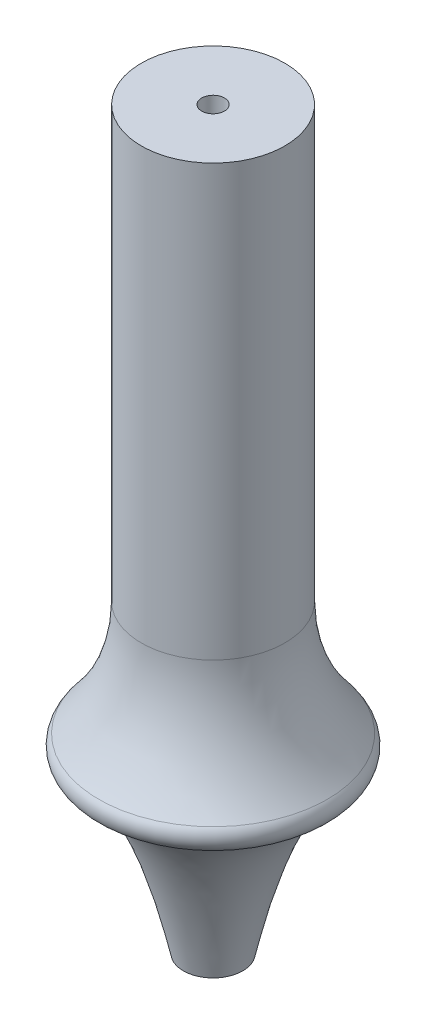
from build123d import *


with BuildPart() as part:
    # Sketch2 → Revolve1 (revolve)
    with BuildSketch(Plane(origin=(0, 0, 0), x_dir=(0, 0, -1), z_dir=(1, 0, 0))):
        with BuildLine():
            Line((-10, 79.984026871), (-10, 20))
            ThreePointArc((-10, 20), (-11.529300925, 11.508521396), (-15.925023202, 4.084129443))
            ThreePointArc((-15.925023202, 4.084129443), (-16.348258147, 2.040451452), (-14.8325, 0.6058))
            add(Edge.make_bspline(
                [(-14.8325, 0.6058), (-14.786589527, 0.594107912), (-14.720151881, 0.577188139), (-14.636942478, 0.555651214), (-14.584628983, 0.541606051), (-14.538694782, 0.529056302), (-14.496115893, 0.516807178), (-14.455377323, 0.504752713), (-14.415703886, 0.492601586), (-14.376608725, 0.480213978), (-14.337823066, 0.467258765), (-14.299073296, 0.453804959), (-14.260077477, 0.439967714), (-14.220832936, 0.425142489), (-14.181003545, 0.409828499), (-14.140639226, 0.39342794), (-14.099539827, 0.376264866), (-14.057643188, 0.358051468), (-14.015003626, 0.338576095), (-13.971270318, 0.318244004), (-13.926716478, 0.296334648), (-13.88091734, 0.273357564), (-13.834012449, 0.248879897), (-13.785997304, 0.222646856), (-13.736545511, 0.195147367), (-13.685880417, 0.165637059), (-13.63383256, 0.134329981), (-13.580202235, 0.101238986), (-13.525196985, 0.065829097), (-13.468489978, 0.028394376), (-13.410218497, -0.011527982), (-13.350168278, -0.053791023), (-13.288470654, -0.098900311), (-13.224788811, -0.146603335), (-13.159241207, -0.197326808), (-13.091855296, -0.251341181), (-13.022233522, -0.308401649), (-12.950733187, -0.369268693), (-12.87684498, -0.433607317), (-12.800942833, -0.50216692), (-12.722558879, -0.574690204), (-12.64180647, -0.651653184), (-12.558631713, -0.733330072), (-12.473007863, -0.820056033), (-12.384606656, -0.911877967), (-12.293655943, -1.009413525), (-12.19993662, -1.112809578), (-12.103181234, -1.222292158), (-12.003658589, -1.33855085), (-11.901000777, -1.461694366), (-11.795279131, -1.592272191), (-11.686428516, -1.730738869), (-11.574152693, -1.877409894), (-11.458536394, -2.032929305), (-11.339441079, -2.197751566), (-11.216906306, -2.372586938), (-11.090456233, -2.557718159), (-10.960339372, -2.754078467), (-10.826403135, -2.962267921), (-10.688322214, -3.182881678), (-10.546388799, -3.416882377), (-10.399982006, -3.664853532), (-10.249381335, -3.927893894), (-10.094533615, -4.206969526), (-9.93478729, -4.502781144), (-9.770600526, -4.816720029), (-9.601692365, -5.149846675), (-9.427661931, -5.50326599), (-9.248775965, -5.878475674), (-9.064645901, -6.276835238), (-8.87533319, -6.699902872), (-8.680516638, -7.149341121), (-8.480119182, -7.626897717), (-8.27419422, -8.134593345), (-8.062173697, -8.674341942), (-7.844473046, -9.248617697), (-7.620378546, -9.859652358), (-7.390143634, -10.510239162), (-7.15351637, -11.203263925), (-6.91022293, -11.941816272), (-6.660409366, -12.729407317), (-6.403463868, -13.569619022), (-6.13955877, -14.466660747), (-5.86859751, -15.425045871), (-5.58995818, -16.449575), (-5.30410545, -17.54587051), (-5.010246169, -18.719716622), (-4.708679684, -19.977884286), (-4.417462856, -21.247043384), (-4.229902291, -22.098318051), (-4.143040834, -22.5)],
                knots=[0, 0, 0, 0, 0.0026864, 0.003887524, 0.004873731, 0.005757813, 0.006587588, 0.007385986, 0.008166831, 0.008940344, 0.009711391, 0.010485479, 0.011266269, 0.012057584, 0.012864206, 0.013685875, 0.014528001, 0.015389717, 0.016276196, 0.017186037, 0.018124349, 0.019091365, 0.020091502, 0.021124214, 0.022193786, 0.02329991, 0.024448714, 0.025637823, 0.026873089, 0.028157979, 0.029490658, 0.030878236, 0.032321667, 0.033824319, 0.035389905, 0.037021117, 0.038721252, 0.040494021, 0.042345363, 0.044276569, 0.046293536, 0.048400508, 0.050601853, 0.052903384, 0.055310916, 0.057829088, 0.060465162, 0.063223709, 0.066113781, 0.069142731, 0.072314292, 0.075640292, 0.079129636, 0.082787821, 0.086628416, 0.090659818, 0.094893736, 0.099340772, 0.104016433, 0.108930498, 0.114098239, 0.119534774, 0.125258904, 0.131284732, 0.137631752, 0.144321681, 0.151373222, 0.158810235, 0.166659266, 0.174942777, 0.183694449, 0.192940456, 0.202718271, 0.21306062, 0.224006047, 0.235599981, 0.247884808, 0.260909978, 0.274731834, 0.289408721, 0.305001629, 0.321583099, 0.339229092, 0.358021891, 0.378056499, 0.39943301, 0.422263423, 0.446671009, 0.472795467, 0.496098755, 0.496098755, 0.496098755, 0.496098755], degree=3))
            Line((-4.143040834, -22.5), (-1.5875, -22.5))
            Line((-1.5875, -22.5), (-1.5875, 79.984026871))
            Line((-1.5875, 79.984026871), (-10, 79.984026871))
        make_face()
    revolve(axis=Axis((0, -48.8258, 0), (0, 1, 0)))


solid = part.part
